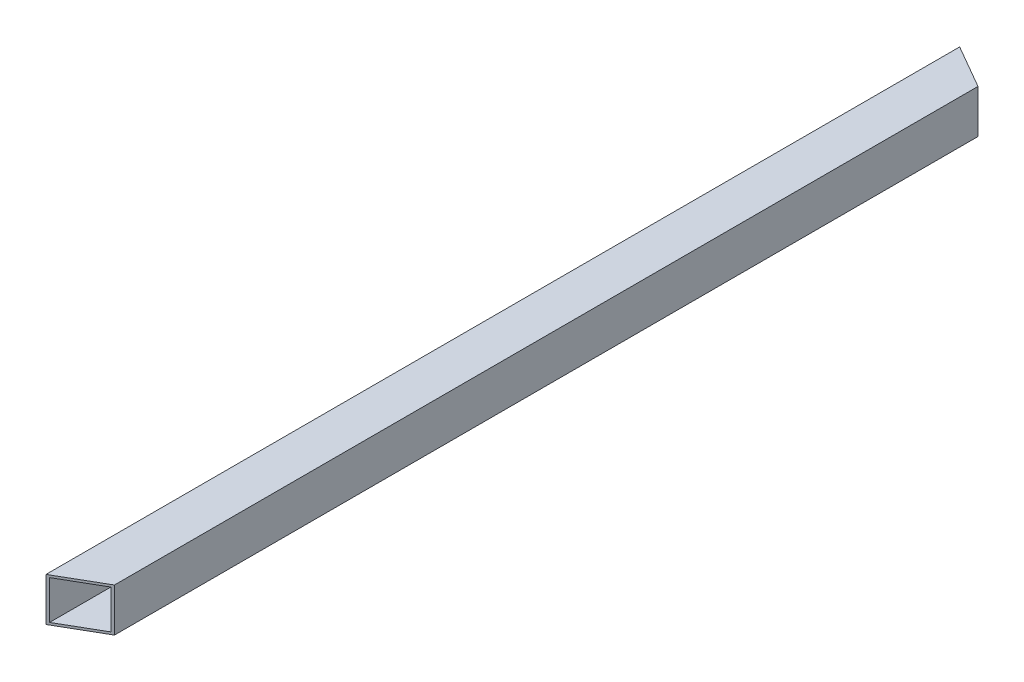
from build123d import *

# Parameters (mm, degrees)
SKETCH1_W               = 19
SKETCH1_H               = 19
SKETCH1_W_2             = 17
SKETCH1_H_2             = 17
BOSS_EXTRUDE1_DEPTH     = 400
CUT_EXTRUDE3_DEPTH      = 1
CUT_EXTRUDE3_DEPTH_BACK = 20
CUT_EXTRUDE4_DEPTH      = 1
CUT_EXTRUDE4_DEPTH_BACK = 20


with BuildPart() as part:
    # Sketch1 → Boss-Extrude1 (new body)
    with BuildSketch(Plane.XY):
        Rectangle(SKETCH1_W, SKETCH1_H)
        Rectangle(SKETCH1_W_2, SKETCH1_H_2, mode=Mode.SUBTRACT)
    extrude(amount=BOSS_EXTRUDE1_DEPTH)

    # Sketch2 → Cut-Extrude3 (cut, two sides)
    with BuildSketch(Plane.XZ.offset(9.5)) as cut_extrude3_sk:
        Polygon((-711.761724625, -405.450995754), (-9.5, 0), (9.5, 10.969655115), (711.761724625, 416.420650868), (1522.663716132, -988.102798381), (99.140266883, -1809.974445003), align=None)
    extrude(amount=CUT_EXTRUDE3_DEPTH, mode=Mode.SUBTRACT)
    extrude(cut_extrude3_sk.sketch, amount=-CUT_EXTRUDE3_DEPTH_BACK, mode=Mode.SUBTRACT)

    # Sketch3 → Cut-Extrude4 (cut, two sides)
    with BuildSketch(Plane(origin=(0, -9.5, 0), x_dir=(-1, 0, 0), z_dir=(0, -1, 0))) as cut_extrude4_sk:
        Polygon((711.761724625, -805.450995754), (9.5, -400), (-9.5, -389.030344885), (-711.761724625, 16.420650868), (-1522.663716132, -1388.102798381), (-99.140266883, -2209.974445003), align=None)
    extrude(amount=CUT_EXTRUDE4_DEPTH, mode=Mode.SUBTRACT)
    extrude(cut_extrude4_sk.sketch, amount=-CUT_EXTRUDE4_DEPTH_BACK, mode=Mode.SUBTRACT)


solid = part.part
